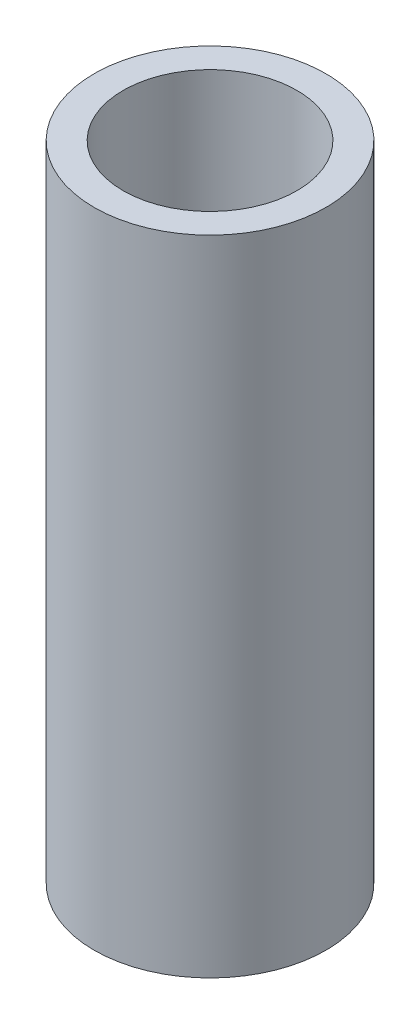
from build123d import *

# Parameters (mm, degrees)
SKETCH1_R           = 25.4
SKETCH1_R_2         = 19.05
BOSS_EXTRUDE1_DEPTH = 141


with BuildPart() as part:
    # Sketch1 → Boss-Extrude1 (new body)
    with BuildSketch(Plane(origin=(0, 0, 0), x_dir=(1, 0, 0), z_dir=(0, 1, 0))):
        with Locations(Location((0, 0, 0), (0, 0, 270))):  # turned: the seam where the file's is
            Circle(SKETCH1_R)
        with Locations(Location((0, 0, 0), (0, 0, 270))):  # turned: the seam where the file's is
            Circle(SKETCH1_R_2, mode=Mode.SUBTRACT)
    extrude(amount=BOSS_EXTRUDE1_DEPTH)


solid = part.part
